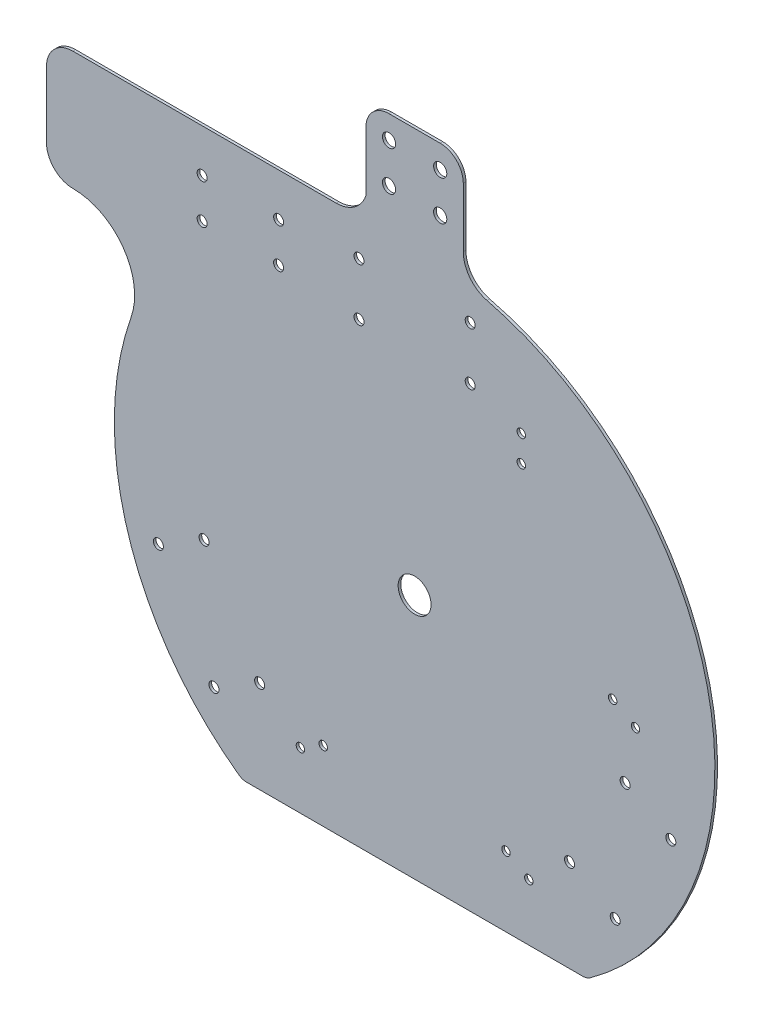
from build123d import *

# Parameters (mm, degrees)
SKETCH1_R           = 2.413
SKETCH1_R_2         = 2.032
SKETCH1_R_3         = 7.9375
SKETCH1_R_4         = 3.175
BOSS_EXTRUDE1_DEPTH = 1.27
SKETCH2_R           = 2.413
CUT_EXTRUDE1_DEPTH  = 2.27
FILLET1_R           = 6.35


with BuildPart() as part:
    # Sketch1 → Boss-Extrude1 (new body)
    with BuildSketch(Plane.XY):
        with BuildLine():
            ThreePointArc((82.933641233, -259.730513994), (142.159112513, -114.876836591), (34.858765173, -0.960728132))
            ThreePointArc((34.858765173, -0.960728132), (26.627499814, 4.377145212), (23.4315, 13.6525))
            Line((23.4315, 13.6525), (23.4315, 42.2275))
            ThreePointArc((23.4315, 42.2275), (20.176724106, 50.085224106), (12.319, 53.34))
            Line((12.319, 53.34), (-12.319, 53.34))
            ThreePointArc((-12.319, 53.34), (-20.176724106, 50.085224106), (-23.4315, 42.2275))
            Line((-23.4315, 42.2275), (-23.4315, 13.6525))
            ThreePointArc((-23.4315, 13.6525), (-28.906938551, 6.162526908), (-37.733581796, 3.30411944))
            Line((-37.733581796, 3.30411944), (-164.5412, 3.30411944))
            ThreePointArc((-164.5412, 3.30411944), (-173.521456121, -0.415624439), (-177.2412, -9.39588056))
            Line((-177.2412, -9.39588056), (-177.2412, -41.275))
            ThreePointArc((-177.2412, -41.275), (-173.521456121, -50.255256121), (-164.5412, -53.975))
            ThreePointArc((-164.5412, -53.975), (-140.291720841, -66.502733348), (-136.476647403, -93.529138158))
            ThreePointArc((-136.476647403, -93.529138158), (-137.626098624, -185.624768634), (-82.933641233, -259.730513994))
            Line((-82.933641233, -259.730513994), (82.933641233, -259.730513994))
        make_face()
        with Locations((-96.602601281, -227.966886439)):
            Circle(SKETCH1_R, mode=Mode.SUBTRACT)
        with Locations((-74.605556024, -215.266886439)):
            Circle(SKETCH1_R, mode=Mode.SUBTRACT)
        with Locations((-123.367851281, -181.608113561)):
            Circle(SKETCH1_R, mode=Mode.SUBTRACT)
        with Locations((-101.370806024, -168.908113561)):
            Circle(SKETCH1_R, mode=Mode.SUBTRACT)
        with Locations((-54.988413477, -232.353774031)):
            Circle(SKETCH1_R_2, mode=Mode.SUBTRACT)
        with Locations((-43.989890849, -226.003774031)):
            Circle(SKETCH1_R_2, mode=Mode.SUBTRACT)
        with Locations((43.989890849, -226.003774031)):
            Circle(SKETCH1_R_2, mode=Mode.SUBTRACT)
        with Locations((54.988413477, -232.353774031)):
            Circle(SKETCH1_R_2, mode=Mode.SUBTRACT)
        with Locations((74.605556024, -215.266886439)):
            Circle(SKETCH1_R, mode=Mode.SUBTRACT)
        with Locations((96.602601281, -227.966886439)):
            Circle(SKETCH1_R, mode=Mode.SUBTRACT)
        with Locations((101.370806024, -168.908113561)):
            Circle(SKETCH1_R, mode=Mode.SUBTRACT)
        with Locations((123.367851281, -181.608113561)):
            Circle(SKETCH1_R, mode=Mode.SUBTRACT)
        with Locations((0, -141.2875)):
            Circle(SKETCH1_R_3, mode=Mode.SUBTRACT)
        with Locations((106.359913477, -143.375725969)):
            Circle(SKETCH1_R_2, mode=Mode.SUBTRACT)
        with Locations((95.361390849, -137.025725969)):
            Circle(SKETCH1_R_2, mode=Mode.SUBTRACT)
        with Locations((-65.4812, -36.5125)):
            Circle(SKETCH1_R, mode=Mode.SUBTRACT)
        with Locations((-26.76525, -39.6875)):
            Circle(SKETCH1_R, mode=Mode.SUBTRACT)
        with Locations((-65.4812, -17.4625)):
            Circle(SKETCH1_R, mode=Mode.SUBTRACT)
        with Locations((-26.76525, -14.2875)):
            Circle(SKETCH1_R, mode=Mode.SUBTRACT)
        with Locations((-12.319, 23.1775)):
            Circle(SKETCH1_R_4, mode=Mode.SUBTRACT)
        with Locations((-12.319, 42.2275)):
            Circle(SKETCH1_R_4, mode=Mode.SUBTRACT)
        with Locations((51.3715, -60.833)):
            Circle(SKETCH1_R_2, mode=Mode.SUBTRACT)
        with Locations((26.76525, -39.6875)):
            Circle(SKETCH1_R, mode=Mode.SUBTRACT)
        with Locations((51.3715, -48.133)):
            Circle(SKETCH1_R_2, mode=Mode.SUBTRACT)
        with Locations((26.76525, -14.2875)):
            Circle(SKETCH1_R, mode=Mode.SUBTRACT)
        with Locations((12.319, 23.1775)):
            Circle(SKETCH1_R_4, mode=Mode.SUBTRACT)
        with Locations((12.319, 42.2275)):
            Circle(SKETCH1_R_4, mode=Mode.SUBTRACT)
    extrude(amount=BOSS_EXTRUDE1_DEPTH)

    # Sketch2 → Cut-Extrude1 (cut, through all)
    with BuildSketch(Plane.XY.offset(1.27)):
        with Locations((-102.3112, -17.4625)):
            Circle(SKETCH2_R)
        with Locations((-102.3112, -36.5125)):
            Circle(SKETCH2_R)
    extrude(amount=-CUT_EXTRUDE1_DEPTH, mode=Mode.SUBTRACT)

    # Fillet1
    fillet1_edges = [part.edges().sort_by_distance(p)[0] for p in [
        (82.933641233, -259.730513994, 0.635),
        (-82.933641233, -259.730513994, 0.635),
    ]]
    fillet(fillet1_edges, radius=FILLET1_R)


solid = part.part
